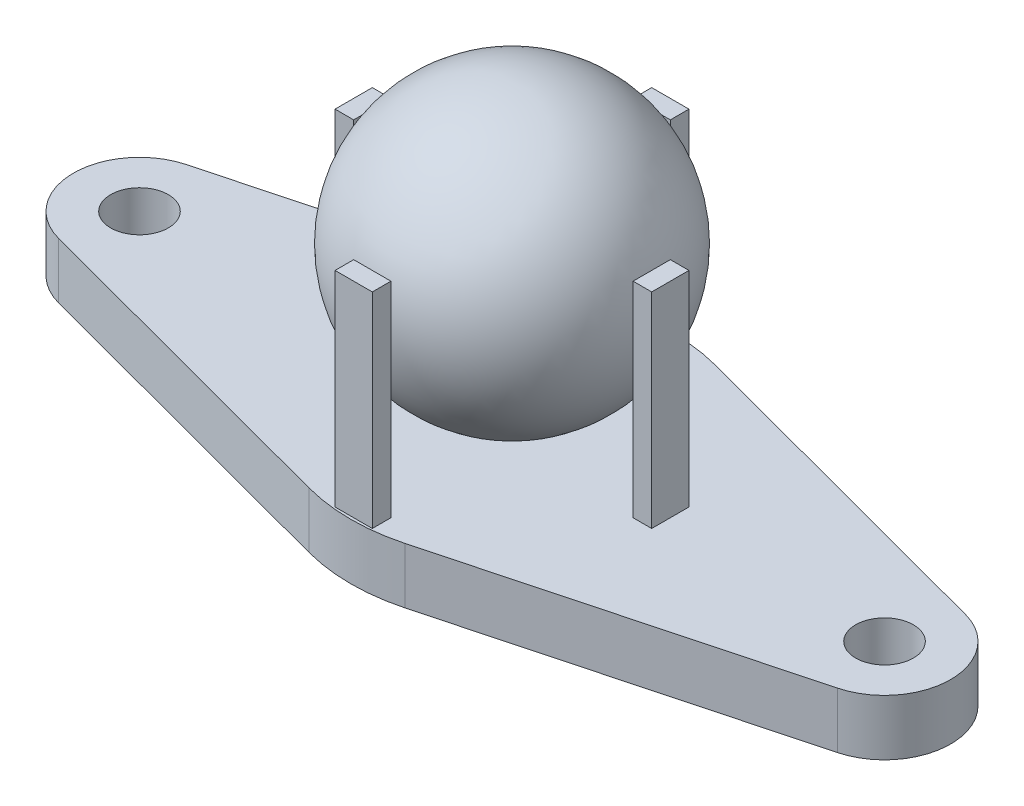
from build123d import *

# Parameters (mm, degrees)
SKETCH2_R           = 1.55
BOSS_EXTRUDE1_DEPTH = 3
FILLET1_R           = 10
SKETCH4_W           = 2
SKETCH4_H           = 1
SKETCH4_W_2         = 1
SKETCH4_H_2         = 2
BOSS_EXTRUDE2_DEPTH = 11


with BuildPart() as part:
    # Sketch2 → Boss-Extrude1 (new body)
    with BuildSketch(Plane(origin=(0, 0, 0), x_dir=(1, 0, 0), z_dir=(0, 1, 0))):
        with BuildLine():
            Line((-20.913570996, 3.430435546), (0, 9))
            Line((0, 9), (20.913570996, 3.430435546))
            ThreePointArc((20.913570996, 3.430435546), (23.55, 0), (20.913570996, -3.430435546))
            Line((20.913570996, -3.430435546), (0, -9))
            Line((0, -9), (-20.913570996, -3.430435546))
            ThreePointArc((-20.913570996, -3.430435546), (-23.55, 0), (-20.913570996, 3.430435546))
        make_face()
        with Locations((-20, 0)):
            Circle(SKETCH2_R, mode=Mode.SUBTRACT)
        with Locations((20, 0)):
            Circle(SKETCH2_R, mode=Mode.SUBTRACT)
    extrude(amount=BOSS_EXTRUDE1_DEPTH)

    # Fillet1
    fillet1_edges = [part.edges().sort_by_distance(p)[0] for p in [
        (0, 1.5, -9),
        (0, 1.5, 9),
    ]]
    fillet(fillet1_edges, radius=FILLET1_R)

    # Sketch4 → Boss-Extrude2 (add)
    with BuildSketch(Plane(origin=(0, 3, 0), x_dir=(1, 0, 0), z_dir=(0, 1, 0))):
        with Locations((0, 8)):
            Rectangle(SKETCH4_W, SKETCH4_H)
        with Locations((8, 0)):
            Rectangle(SKETCH4_W_2, SKETCH4_H_2)
        with Locations((0, -8)):
            Rectangle(SKETCH4_W, SKETCH4_H)
        with Locations((-8, 0)):
            Rectangle(SKETCH4_W_2, SKETCH4_H_2)
    extrude(amount=BOSS_EXTRUDE2_DEPTH)


with BuildPart() as body_2:
    # Sketch3 → Revolve1 (revolve)
    with BuildSketch(Plane.XY):
        with BuildLine():
            Line((0, 19), (0, 4))
            ThreePointArc((0, 4), (-7.5, 11.5), (0, 19))
        make_face()
    revolve(axis=Axis((0, 0, 0), (0, 1, 0)))


solid = Compound([part.part, body_2.part])
